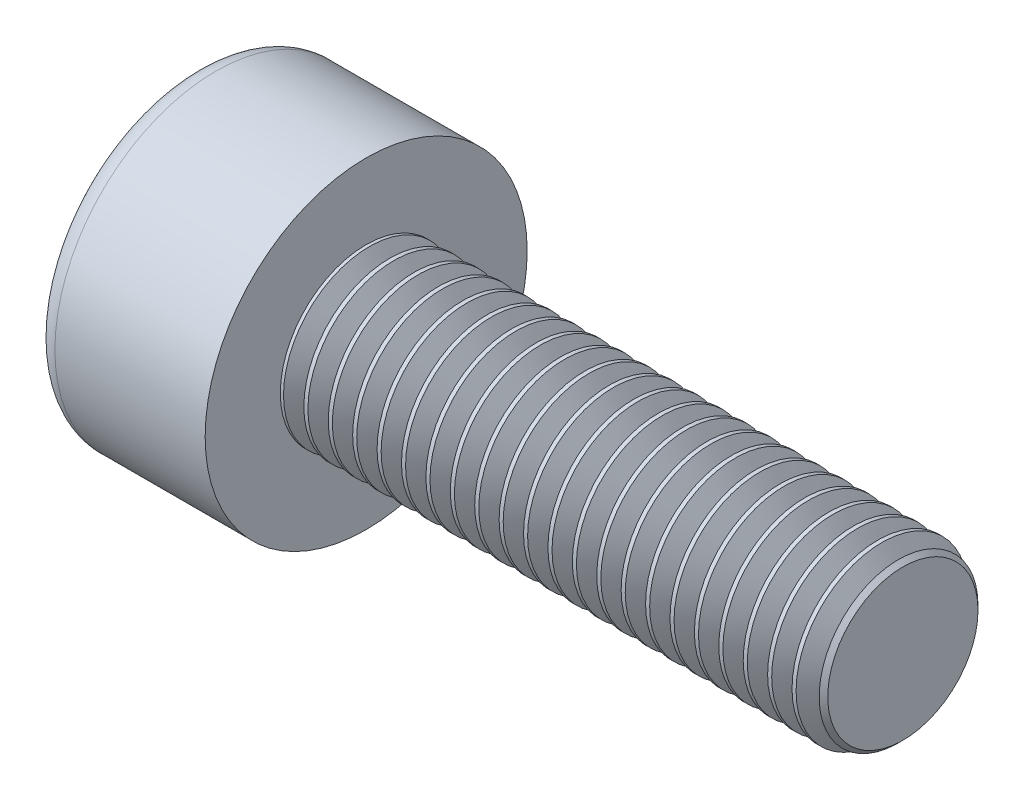
from build123d import *

# Parameters (mm, degrees)
SKETCH1_R           = 1.5
BASEHEAD_DEPTH      = 1.6
SKETCH2_R           = 0.8
BASEBODY_DEPTH      = 5
HEXAGONSOCKET_DEPTH = 0.7
TOPFILLET_R         = 0.2
CHAMFER1_SIZE       = 0.1
LPATTERN10_COUNT    = 22
LPATTERN10_PITCH    = 0.2274


with BuildPart() as part:
    # Sketch1 → BaseHead (new body)
    with BuildSketch(Plane(origin=(0, 0, 0), x_dir=(0, 0, -1), z_dir=(1, 0, 0))):
        Circle(SKETCH1_R)
    extrude(amount=BASEHEAD_DEPTH)

    # Sketch2 → BaseBody (add)
    with BuildSketch(Plane(origin=(1.6, 0, 0), x_dir=(0, 0, -1), z_dir=(1, 0, 0))):
        Circle(SKETCH2_R)
    extrude(amount=BASEBODY_DEPTH)

    # Sketch3 → HexagonSocket (cut)
    with BuildSketch(Plane(origin=(0, 0, 0), x_dir=(0, 0, -1), z_dir=(1, 0, 0))):
        Polygon((0.866025404, 0), (0.433012702, 0.75), (-0.433012702, 0.75), (-0.866025404, 0), (-0.433012702, -0.75), (0.433012702, -0.75), align=None)
    extrude(amount=HEXAGONSOCKET_DEPTH, mode=Mode.SUBTRACT)

    # Sketch4 → Cut-Revolve1 (revolve, cut)
    with BuildSketch(Plane(origin=(-4.19613823, 0.75, 0), x_dir=(-1, 0, 0), z_dir=(0, 0, 1))):
        Polygon((-4.89613823, 1.5), (-5.329150931, 0.75), (-4.89613823, 0.75), align=None)
    revolve(axis=Axis((0.838992387, 0, 0), (-1, 0, 0)), mode=Mode.SUBTRACT)

    # TopFillet
    topfillet_edges = [part.edges().sort_by_distance(p)[0] for p in [
        (0, 0, 1.5),
    ]]
    fillet(topfillet_edges, radius=TOPFILLET_R)

    # Chamfer1
    chamfer1_edges = [part.edges().sort_by_distance(p)[0] for p in [
        (6.6, 0, 0.8),
    ]]
    chamfer(chamfer1_edges, length=CHAMFER1_SIZE)

    # Sketch5 → Cut-Revolve10 (revolve, cut)
    with BuildSketch(Plane.XY):
        Polygon((6.5, 0.635888186), (6.59475, 0.8), (6.59475, 0.9895), (6.40525, 0.9895), (6.40525, 0.8), align=None)
    cut_revolve10 = revolve(axis=Axis((0, 0, 0), (1, 0, 0)), mode=Mode.SUBTRACT)

    # LPattern10: Cut-Revolve10 ×22
    with Locations(*[(-i * LPATTERN10_PITCH, 0, 0) for i in range(1, LPATTERN10_COUNT)]):
        add(cut_revolve10, mode=Mode.SUBTRACT)


solid = part.part
